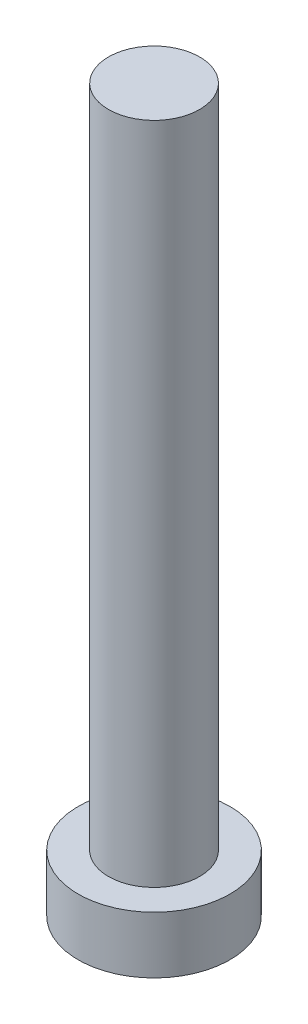
from build123d import *

# Parameters (mm, degrees)
SKETCH1_R           = 3.048
BOSS_EXTRUDE1_DEPTH = 44.45
SKETCH2_R           = 5.08
BOSS_EXTRUDE2_DEPTH = 3.81


with BuildPart() as part:
    # Sketch1 → Boss-Extrude1 (new body)
    with BuildSketch(Plane(origin=(0, 0, 0), x_dir=(1, 0, 0), z_dir=(0, 1, 0))):
        Circle(SKETCH1_R)
    extrude(amount=BOSS_EXTRUDE1_DEPTH)

    # Sketch2 → Boss-Extrude2 (add)
    with BuildSketch(Plane.XZ):
        Circle(SKETCH2_R)
    extrude(amount=BOSS_EXTRUDE2_DEPTH)


solid = part.part
